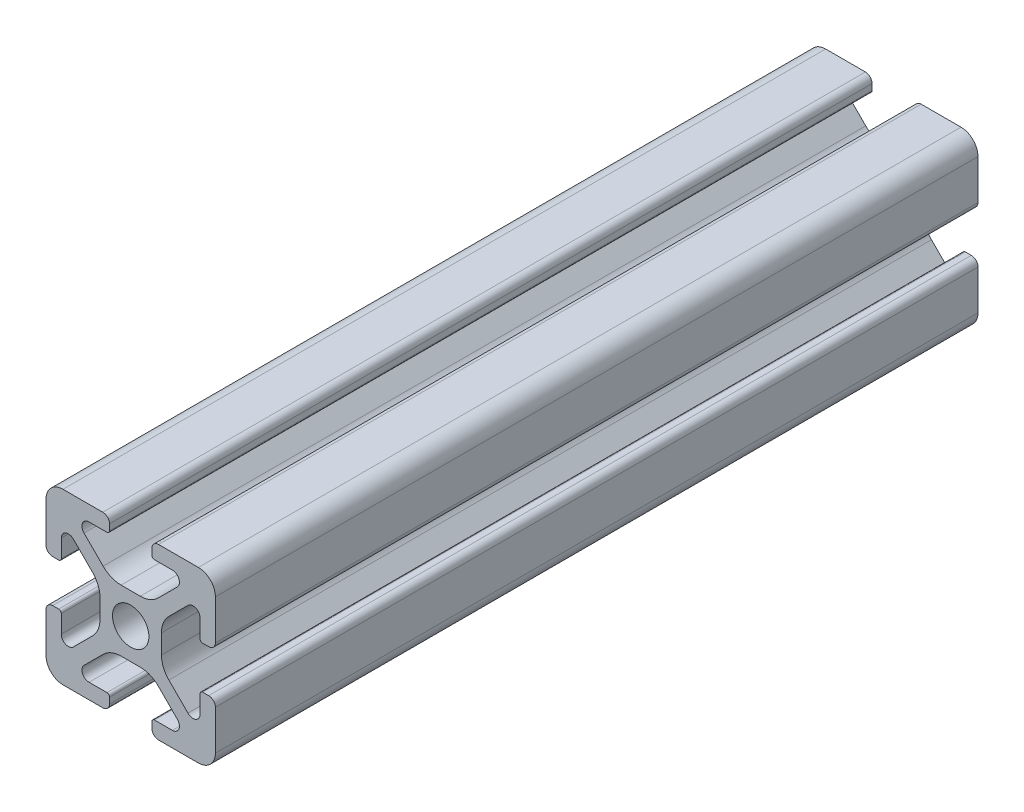
from build123d import *

# Parameters (mm, degrees)
SKETCH1_R           = 2.1463
BOSS_EXTRUDE1_DEPTH = 45


with BuildPart() as part:
    # Sketch1 → Boss-Extrude1 (new body, symmetric)
    with BuildSketch(Plane.XY):
        with BuildLine():
            Line((-9.9949, 7.9883), (-9.9949, 3.2893))
            ThreePointArc((-9.9949, 3.2893), (-9.76427588, 2.73252412), (-9.2075, 2.5019))
            Line((-9.2075, 2.5019), (-8.4963, 2.5019))
            ThreePointArc((-8.4963, 2.5019), (-8.280773853, 2.591173853), (-8.1915, 2.8067))
            Line((-8.1915, 2.8067), (-8.1915, 4.9149))
            ThreePointArc((-8.1915, 4.9149), (-7.674065253, 5.689295824), (-6.760603096, 5.507596904))
            Line((-6.760603096, 5.507596904), (-4.505765747, 3.252759555))
            ThreePointArc((-4.505765747, 3.252759555), (-3.856054457, 2.280397894), (-3.627906192, 1.133419111))
            Line((-3.627906192, 1.133419111), (-3.627906192, -1.133419111))
            ThreePointArc((-3.627906192, -1.133419111), (-3.856054457, -2.280397894), (-4.505765747, -3.252759555))
            Line((-4.505765747, -3.252759555), (-6.760603096, -5.507596904))
            ThreePointArc((-6.760603096, -5.507596904), (-7.674065253, -5.689295824), (-8.1915, -4.9149))
            Line((-8.1915, -4.9149), (-8.1915, -2.8067))
            ThreePointArc((-8.1915, -2.8067), (-8.280773853, -2.591173853), (-8.4963, -2.5019))
            Line((-8.4963, -2.5019), (-9.2075, -2.5019))
            ThreePointArc((-9.2075, -2.5019), (-9.76427588, -2.73252412), (-9.9949, -3.2893))
            Line((-9.9949, -3.2893), (-9.9949, -7.9883))
            ThreePointArc((-9.9949, -7.9883), (-9.407180467, -9.407180467), (-7.9883, -9.9949))
            Line((-7.9883, -9.9949), (-3.2893, -9.9949))
            ThreePointArc((-3.2893, -9.9949), (-2.73252412, -9.76427588), (-2.5019, -9.2075))
            Line((-2.5019, -9.2075), (-2.5019, -8.4963))
            ThreePointArc((-2.5019, -8.4963), (-2.591173853, -8.280773853), (-2.8067, -8.1915))
            Line((-2.8067, -8.1915), (-4.9149, -8.1915))
            ThreePointArc((-4.9149, -8.1915), (-5.689295824, -7.674065253), (-5.507596904, -6.760603096))
            Line((-5.507596904, -6.760603096), (-3.252759555, -4.505765747))
            ThreePointArc((-3.252759555, -4.505765747), (-2.280397894, -3.856054457), (-1.133419111, -3.627906192))
            Line((-1.133419111, -3.627906192), (1.133419111, -3.627906192))
            ThreePointArc((1.133419111, -3.627906192), (2.280397894, -3.856054457), (3.252759555, -4.505765747))
            Line((3.252759555, -4.505765747), (5.507596904, -6.760603096))
            ThreePointArc((5.507596904, -6.760603096), (5.689295824, -7.674065253), (4.9149, -8.1915))
            Line((4.9149, -8.1915), (2.8067, -8.1915))
            ThreePointArc((2.8067, -8.1915), (2.591173853, -8.280773853), (2.5019, -8.4963))
            Line((2.5019, -8.4963), (2.5019, -9.2075))
            ThreePointArc((2.5019, -9.2075), (2.73252412, -9.76427588), (3.2893, -9.9949))
            Line((3.2893, -9.9949), (7.9883, -9.9949))
            ThreePointArc((7.9883, -9.9949), (9.407180467, -9.407180467), (9.9949, -7.9883))
            Line((9.9949, -7.9883), (9.9949, -3.2893))
            ThreePointArc((9.9949, -3.2893), (9.76427588, -2.73252412), (9.2075, -2.5019))
            Line((9.2075, -2.5019), (8.4963, -2.5019))
            ThreePointArc((8.4963, -2.5019), (8.280773853, -2.591173853), (8.1915, -2.8067))
            Line((8.1915, -2.8067), (8.1915, -4.9149))
            ThreePointArc((8.1915, -4.9149), (7.674065253, -5.689295824), (6.760603096, -5.507596904))
            Line((6.760603096, -5.507596904), (4.505765747, -3.252759555))
            ThreePointArc((4.505765747, -3.252759555), (3.856054457, -2.280397894), (3.627906192, -1.133419111))
            Line((3.627906192, -1.133419111), (3.627906192, 1.133419111))
            ThreePointArc((3.627906192, 1.133419111), (3.856054457, 2.280397894), (4.505765747, 3.252759555))
            Line((4.505765747, 3.252759555), (6.760603096, 5.507596904))
            ThreePointArc((6.760603096, 5.507596904), (7.674065253, 5.689295824), (8.1915, 4.9149))
            Line((8.1915, 4.9149), (8.1915, 2.8067))
            ThreePointArc((8.1915, 2.8067), (8.280773853, 2.591173853), (8.4963, 2.5019))
            Line((8.4963, 2.5019), (9.2075, 2.5019))
            ThreePointArc((9.2075, 2.5019), (9.76427588, 2.73252412), (9.9949, 3.2893))
            Line((9.9949, 3.2893), (9.9949, 7.9883))
            ThreePointArc((9.9949, 7.9883), (9.407180467, 9.407180467), (7.9883, 9.9949))
            Line((7.9883, 9.9949), (3.2893, 9.9949))
            ThreePointArc((3.2893, 9.9949), (2.73252412, 9.76427588), (2.5019, 9.2075))
            Line((2.5019, 9.2075), (2.5019, 8.4963))
            ThreePointArc((2.5019, 8.4963), (2.591173853, 8.280773853), (2.8067, 8.1915))
            Line((2.8067, 8.1915), (4.9149, 8.1915))
            ThreePointArc((4.9149, 8.1915), (5.689295824, 7.674065253), (5.507596904, 6.760603096))
            Line((5.507596904, 6.760603096), (3.252759555, 4.505765747))
            ThreePointArc((3.252759555, 4.505765747), (2.280397894, 3.856054457), (1.133419111, 3.627906192))
            Line((1.133419111, 3.627906192), (-1.133419111, 3.627906192))
            ThreePointArc((-1.133419111, 3.627906192), (-2.280397894, 3.856054457), (-3.252759555, 4.505765747))
            Line((-3.252759555, 4.505765747), (-5.507596904, 6.760603096))
            ThreePointArc((-5.507596904, 6.760603096), (-5.689295824, 7.674065253), (-4.9149, 8.1915))
            Line((-4.9149, 8.1915), (-2.8067, 8.1915))
            ThreePointArc((-2.8067, 8.1915), (-2.591173853, 8.280773853), (-2.5019, 8.4963))
            Line((-2.5019, 8.4963), (-2.5019, 9.2075))
            ThreePointArc((-2.5019, 9.2075), (-2.73252412, 9.76427588), (-3.2893, 9.9949))
            Line((-3.2893, 9.9949), (-7.9883, 9.9949))
            ThreePointArc((-7.9883, 9.9949), (-9.407180467, 9.407180467), (-9.9949, 7.9883))
        make_face()
        Circle(SKETCH1_R, mode=Mode.SUBTRACT)
    extrude(amount=BOSS_EXTRUDE1_DEPTH, both=True)


solid = part.part
